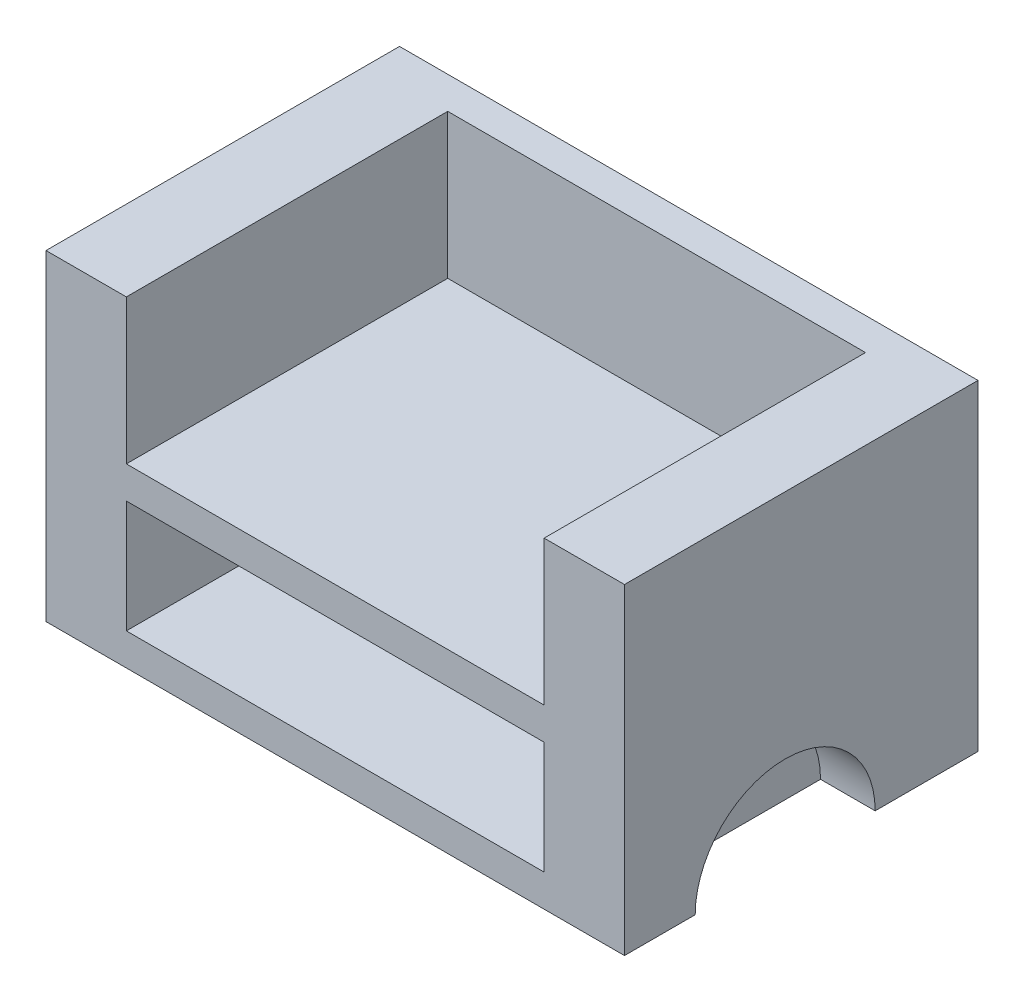
from build123d import *

# Parameters (mm, degrees)
SKETCH1_W           = 180
SKETCH1_H           = 120
BOSS_EXTRUDE1_DEPTH = 100
SKETCH2_W           = 130
SKETCH2_H           = 100
CUT_EXTRUDE1_DEPTH  = 90
CUT_EXTRUDE2_DEPTH  = 17
CUT_EXTRUDE3_DEPTH  = 17
CUT_EXTRUDE4_START  = -100
SKETCH6_W           = 180
SKETCH6_H           = 10
CUT_EXTRUDE4_DEPTH  = 100
SKETCH7_W           = 130
SKETCH7_H           = 10
BOSS_EXTRUDE2_DEPTH = 100


with BuildPart() as part:
    # Sketch1 → Boss-Extrude1 (new body)
    with BuildSketch(Plane(origin=(0, 0, 0), x_dir=(1, 0, 0), z_dir=(0, 1, 0))):
        with Locations((90, 60)):
            Rectangle(SKETCH1_W, SKETCH1_H)
    extrude(amount=BOSS_EXTRUDE1_DEPTH)

    # Sketch2 → Cut-Extrude1 (cut)
    with BuildSketch(Plane(origin=(0, 100, 0), x_dir=(1, 0, 0), z_dir=(0, 1, 0))):
        with Locations((90, 60)):
            Rectangle(SKETCH2_W, SKETCH2_H)
    extrude(amount=-CUT_EXTRUDE1_DEPTH, mode=Mode.SUBTRACT)

    # Sketch3 → Cut-Extrude2 (cut)
    with BuildSketch(Plane(origin=(180, 0, 0), x_dir=(0, 0, -1), z_dir=(1, 0, 0))):
        with BuildLine():
            Line((32, 0), (88, 0))
            ThreePointArc((88, 0), (60, 28), (32, 0))
        make_face()
    extrude(amount=-CUT_EXTRUDE2_DEPTH, mode=Mode.SUBTRACT)

    # Sketch5 → Cut-Extrude3 (cut)
    with BuildSketch(Plane.ZY):
        with BuildLine():
            Line((-88, 0), (-32, 0))
            ThreePointArc((-32, 0), (-60, 28), (-88, 0))
        make_face()
    extrude(amount=-CUT_EXTRUDE3_DEPTH, mode=Mode.SUBTRACT)

    # Sketch6 → Cut-Extrude4 (cut)
    with BuildSketch(Plane(origin=(0, 100, 0), x_dir=(1, 0, 0), z_dir=(0, 1, 0)).offset(CUT_EXTRUDE4_START)):
        with Locations((90, 5)):
            Rectangle(SKETCH6_W, SKETCH6_H)
    extrude(amount=CUT_EXTRUDE4_DEPTH, mode=Mode.SUBTRACT)

    # Sketch7 → Boss-Extrude2 (add)
    with BuildSketch(Plane.XY.offset(-110)):
        with Locations((90, 50)):
            Rectangle(SKETCH7_W, SKETCH7_H)
    extrude(amount=BOSS_EXTRUDE2_DEPTH)


solid = part.part
